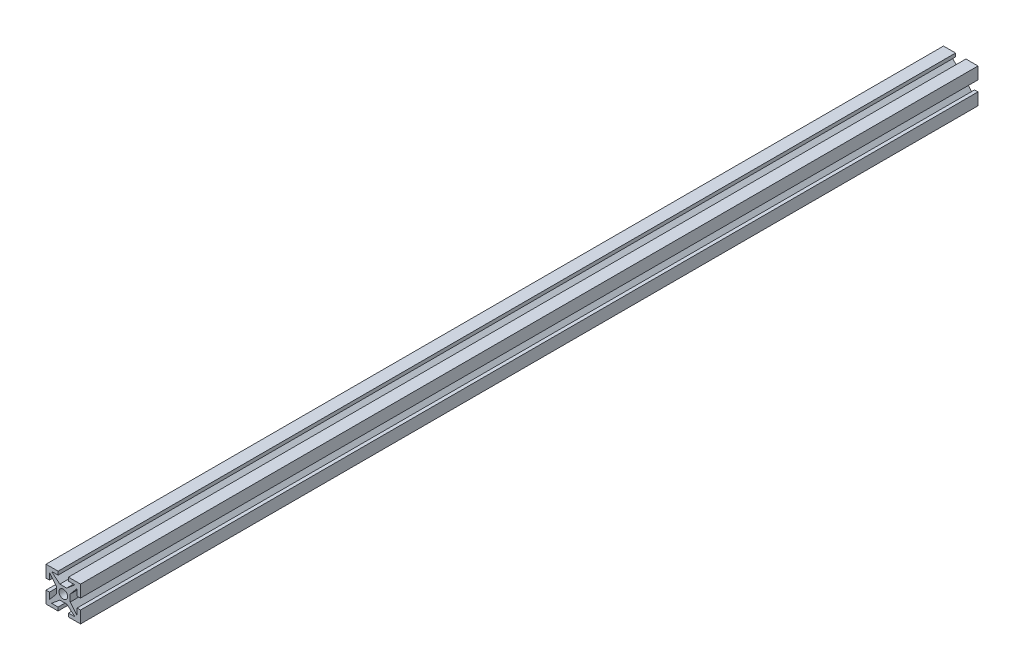
from build123d import *

# Parameters (mm, degrees)
ESQUISSE2_R          = 1.25
MAIN_EXTRUSION_DEPTH = 260


with BuildPart() as part:
    # Esquisse2 → Main Extrusion (new body)
    with BuildSketch(Plane.XY):
        Polygon((-1, -2), (1, -2), (3.383507185, -4), (1.5, -4), (1.5, -5), (5, -5), (5, -1.5), (4, -1.5), (4, -3.383507185), (2, -1), (2, 1), (4, 3.383507185), (4, 1.5), (5, 1.5), (5, 5), (1.5, 5), (1.5, 4), (3.383507185, 4), (1, 2), (-1, 2), (-3.383507185, 4), (-1.5, 4), (-1.5, 5), (-5, 5), (-5, 1.5), (-4, 1.5), (-4, 3.383507185), (-2, 1), (-2, -1), (-4, -3.383507185), (-4, -1.5), (-5, -1.5), (-5, -5), (-1.5, -5), (-1.5, -4), (-3.383507185, -4), align=None)
        Circle(ESQUISSE2_R, mode=Mode.SUBTRACT)
    extrude(amount=MAIN_EXTRUSION_DEPTH)


solid = part.part
